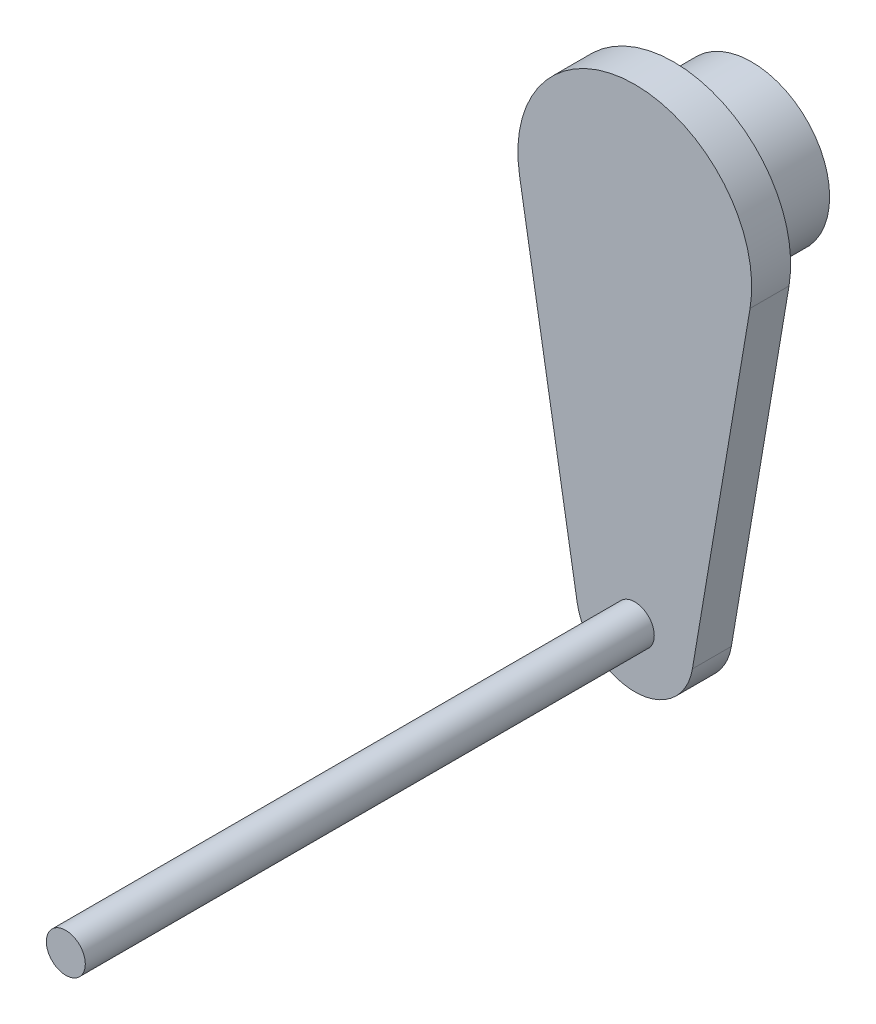
from build123d import *

# Parameters (mm, degrees)
SKETCH1_R           = 12.7
BOSS_EXTRUDE1_DEPTH = 12.7
SKETCH1_3_R         = 3.175
BOSS_EXTRUDE2_DEPTH = 6.35
SKETCH1_4_R         = 3.175
BOSS_EXTRUDE3_DEPTH = 99.06


with BuildPart() as part:
    # Sketch1 → Boss-Extrude1 (new body)
    with BuildSketch(Plane.XY):
        Circle(SKETCH1_R)
    extrude(amount=-BOSS_EXTRUDE1_DEPTH)

    # Sketch1_3 → Boss-Extrude2 (add)
    with BuildSketch(Plane.XY):
        with BuildLine():
            Line((9.391776656, -58.7375), (18.783553311, -3.175))
            ThreePointArc((18.783553311, -3.175), (0, 19.05), (-18.783553311, -3.175))
            Line((-18.783553311, -3.175), (-9.391776656, -58.7375))
            ThreePointArc((-9.391776656, -58.7375), (0, -66.675), (9.391776656, -58.7375))
        make_face()
        with Locations((0, -57.15)):
            Circle(SKETCH1_3_R, mode=Mode.SUBTRACT)
    extrude(amount=BOSS_EXTRUDE2_DEPTH)

    # Sketch1_4 → Boss-Extrude3 (add)
    with BuildSketch(Plane.XY):
        with Locations((0, -57.15)):
            Circle(SKETCH1_4_R)
    extrude(amount=BOSS_EXTRUDE3_DEPTH)


solid = part.part
